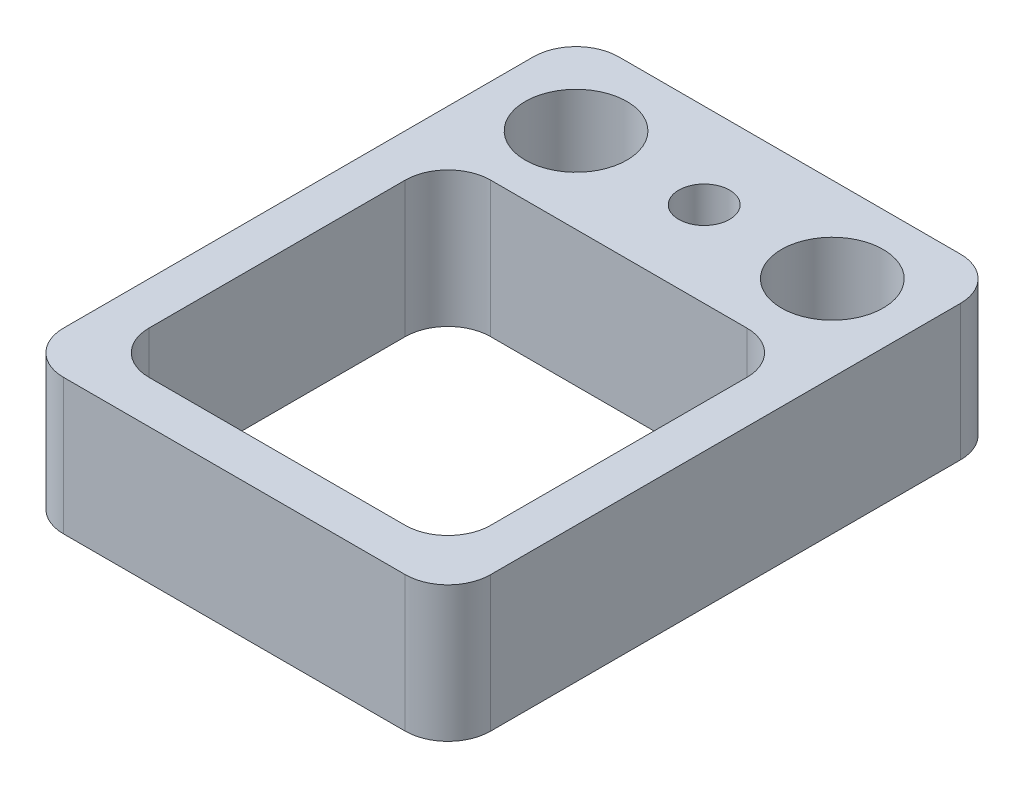
from build123d import *

# Parameters (mm, degrees)
SKETCH1_W                           = 10
SKETCH1_H                           = 13
EXTRUDE1_DEPTH                      = 3.175
SKETCH2_W                           = 8
SKETCH2_H                           = 8
EXTRUDE2_DEPTH                      = 3.5
F_0_80_TAPPED_HOLE1_D               = 1.19126
F_0_80_TAPPED_HOLE1_DEPTH           = 4
F_0_80_TAPPED_HOLE1_TIP             = 0.357890611
F_3_32_0_09375_DIAMETER_HOLE1_D     = 2.38125
F_3_32_0_09375_DIAMETER_HOLE1_DEPTH = 10
F_3_32_0_09375_DIAMETER_HOLE1_TIP   = 0.715399675
FILLET7_R                           = 1


with BuildPart() as part:
    # Sketch1 → Extrude1 (new body)
    with BuildSketch(Plane(origin=(0, 0, 0), x_dir=(1, 0, 0), z_dir=(0, 1, 0))):
        Rectangle(SKETCH1_W, SKETCH1_H)
    extrude(amount=EXTRUDE1_DEPTH)

    # Sketch2 → Extrude2 (cut)
    with BuildSketch(Plane(origin=(0, 3.175, 0), x_dir=(1, 0, 0), z_dir=(0, 1, 0))):
        with Locations((0, -1.5)):
            Rectangle(SKETCH2_W, SKETCH2_H)
    extrude(amount=-EXTRUDE2_DEPTH, mode=Mode.SUBTRACT)

    # #0-80 Tapped Hole1
    with Locations(Plane(origin=(0, 3.175, -4.5), x_dir=(0, 0, 1), z_dir=(0, 1, 0))):
        with Locations((0, 0)):
            Hole(F_0_80_TAPPED_HOLE1_D / 2, depth=F_0_80_TAPPED_HOLE1_DEPTH)
            with Locations((0, 0, -(F_0_80_TAPPED_HOLE1_DEPTH + F_0_80_TAPPED_HOLE1_TIP / 2))):  # 118° drill point
                Cone(0, F_0_80_TAPPED_HOLE1_D / 2, F_0_80_TAPPED_HOLE1_TIP, mode=Mode.SUBTRACT)

    # 3/32 (0.09375) Diameter Hole1
    with Locations(Plane(origin=(-3, 3.175, -4.5), x_dir=(0, 0, 1), z_dir=(0, 1, 0))):
        with Locations((0, 0), (0, 6)):
            Hole(F_3_32_0_09375_DIAMETER_HOLE1_D / 2, depth=F_3_32_0_09375_DIAMETER_HOLE1_DEPTH)
            with Locations((0, 0, -(F_3_32_0_09375_DIAMETER_HOLE1_DEPTH + F_3_32_0_09375_DIAMETER_HOLE1_TIP / 2))):  # 118° drill point
                Cone(0, F_3_32_0_09375_DIAMETER_HOLE1_D / 2, F_3_32_0_09375_DIAMETER_HOLE1_TIP, mode=Mode.SUBTRACT)

    # Fillet7
    fillet7_edges = [part.edges().sort_by_distance(p)[0] for p in [
        (-4, 1.5875, 5.5),
        (-4, 1.5875, -2.5),
        (4, 1.5875, -2.5),
        (4, 1.5875, 5.5),
        (-5, 1.5875, -6.5),
        (5, 1.5875, -6.5),
        (5, 1.5875, 6.5),
        (-5, 1.5875, 6.5),
    ]]
    fillet(fillet7_edges, radius=FILLET7_R)


solid = part.part
